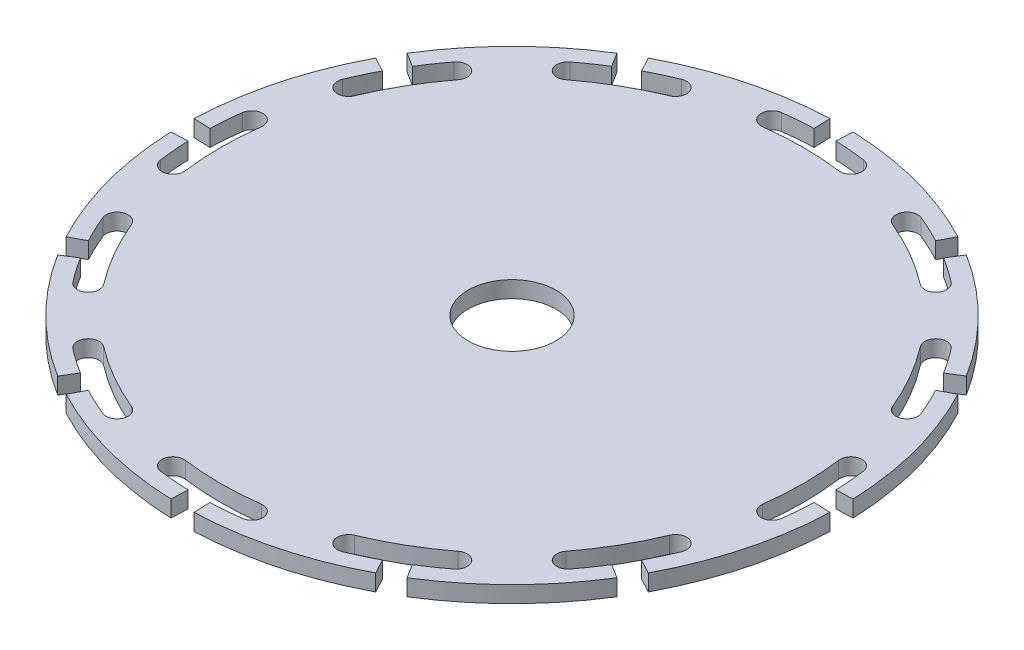
from build123d import *

# Parameters (mm, degrees)
SKETCH1_R         = 30
WHEEL_BLANK_DEPTH = 1.5
T_SLOT_DEPTH      = 2.5
CIRPATTERN1_COUNT = 12
SKETCH3_R         = 4
CENTER_HOLE_DEPTH = 6


with BuildPart() as part:
    # Sketch1 → Wheel Blank (new body)
    with BuildSketch(Plane(origin=(0, 0, 0), x_dir=(1, 0, 0), z_dir=(0, 1, 0))):
        Circle(SKETCH1_R)
    extrude(amount=WHEEL_BLANK_DEPTH)

    # Sketch2 → T-Slot (cut, through all)
    with BuildSketch(Plane(origin=(0, 0, 0), x_dir=(1, 0, 0), z_dir=(0, 1, 0))):
        with BuildLine():
            Line((-1.046984901, 29.981724811), (-0.994635656, 28.48263857))
            ThreePointArc((-0.994635656, 28.48263857), (-2.360033914, 28.402116821), (-3.719996478, 28.256178549))
            ThreePointArc((-3.719996478, 28.256178549), (-4.580915147, 27.134207496), (-3.458944094, 26.273288826))
            ThreePointArc((-3.458944094, 26.273288826), (0, 26.5), (3.458944094, 26.273288826))
            ThreePointArc((3.458944094, 26.273288826), (4.580915147, 27.134207496), (3.719996478, 28.256178549))
            ThreePointArc((3.719996478, 28.256178549), (2.360033914, 28.402116821), (0.994635656, 28.48263857))
            Line((0.994635656, 28.48263857), (1.046984901, 29.981724811))
            ThreePointArc((1.046984901, 29.981724811), (0, 30), (-1.046984901, 29.981724811))
        make_face()
    t_slot = extrude(amount=T_SLOT_DEPTH, mode=Mode.SUBTRACT)

    # CirPattern1: T-Slot ×12 about axis
    cirpattern1_axis = Axis((0, 0, 0), (0, 1, 0))
    for i in range(1, CIRPATTERN1_COUNT):
        add(t_slot.rotate(cirpattern1_axis, i * 360 / CIRPATTERN1_COUNT), mode=Mode.SUBTRACT)

    # Sketch3 → Center Hole (cut)
    with BuildSketch(Plane(origin=(0, 0, 0), x_dir=(1, 0, 0), z_dir=(0, 1, 0))):
        Circle(SKETCH3_R)
    extrude(amount=CENTER_HOLE_DEPTH, mode=Mode.SUBTRACT)


solid = part.part
